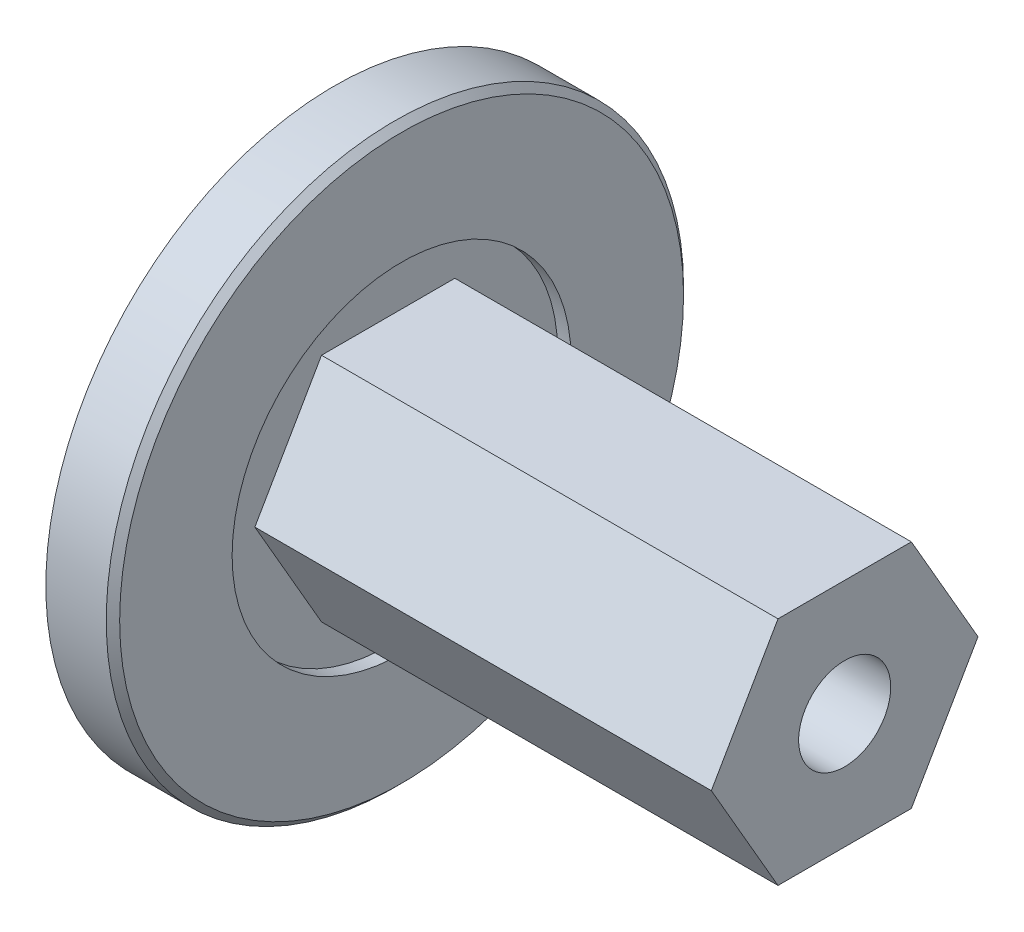
from build123d import *
from build123d.topology import SkipClean

# Parameters (mm, degrees)
SKETCH1_R               = 21.5
BOSS_EXTRUDE1_DEPTH     = 4
SKETCH2_R               = 21.5
SKETCH2_R_2             = 12.625
BOSS_EXTRUDE2_DEPTH     = 1
CUT_EXTRUDE1_DEPTH      = 31.813957876
CUT_EXTRUDE1_DEPTH_BACK = 31.813957876
SKETCH3_R               = 3.429
SKETCH4_R               = 3.429
BOSS_EXTRUDE3_DEPTH     = 34
CHAMFER1_SIZE           = 0.5


with BuildPart() as part:
    # Sketch1 → Boss-Extrude1 (new body)
    with BuildSketch(Plane(origin=(0, 0, 0), x_dir=(0, 0, -1), z_dir=(1, 0, 0))):
        Circle(SKETCH1_R)
    extrude(amount=BOSS_EXTRUDE1_DEPTH)

    # Sketch2 → Boss-Extrude2 (add)
    with BuildSketch(Plane(origin=(4, 0, 0), x_dir=(0, 0, -1), z_dir=(1, 0, 0))):
        Circle(SKETCH2_R)
        Circle(SKETCH2_R_2, mode=Mode.SUBTRACT)
    extrude(amount=BOSS_EXTRUDE2_DEPTH)

    # Sketch3 → Cut-Extrude1 (cut, two sides: drawn at the far end of the back side and taken through both)
    with BuildSketch(Plane.ZY.offset(-CUT_EXTRUDE1_DEPTH_BACK)):
        Circle(SKETCH3_R)
    extrude(amount=CUT_EXTRUDE1_DEPTH + CUT_EXTRUDE1_DEPTH_BACK, mode=Mode.SUBTRACT)

    # Sketch4 → Boss-Extrude3 (add)
    with SkipClean():  # the faces are left unmerged after this step: merging them gives an invalid solid
        with BuildSketch(Plane(origin=(4, 0, 0), x_dir=(0, 0, -1), z_dir=(1, 0, 0))):
            Polygon((4.965212315, -8.6), (9.93042463, 0), (4.965212315, 8.6), (-4.965212315, 8.6), (-9.93042463, 0), (-4.965212315, -8.6), align=None)
            Circle(SKETCH4_R, mode=Mode.SUBTRACT)
        extrude(amount=BOSS_EXTRUDE3_DEPTH)

    # Chamfer1
    chamfer1_edges = [part.edges().sort_by_distance(p)[0] for p in [
        (5, 0, 21.5),
    ]]
    chamfer(chamfer1_edges, length=CHAMFER1_SIZE)


solid = part.part
